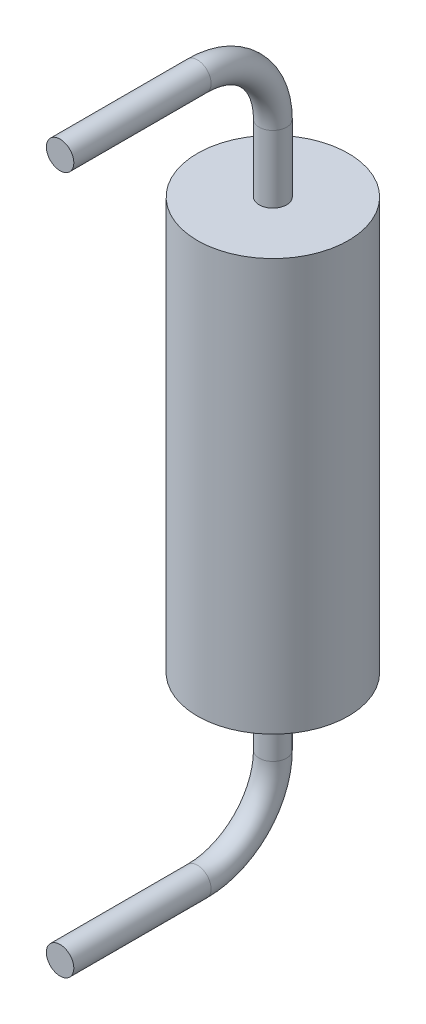
from build123d import *

# Parameters (mm, degrees)
BOSS_EXTRUDE1_DEPTH      = 3
BOSS_EXTRUDE1_DEPTH_BACK = 3
SKETCH2_R                = 1.1
SWEEP1_PROFILE_R         = 0.2


with BuildPart() as part:
    # Sketch2 → Boss-Extrude1 (new, two sides: drawn at the far end of the back side and taken through both)
    with BuildSketch(Plane(origin=(0, 0, 0), x_dir=(1, 0, 0), z_dir=(0, 1, 0)).offset(-BOSS_EXTRUDE1_DEPTH_BACK)):
        Circle(SKETCH2_R)
    extrude(amount=BOSS_EXTRUDE1_DEPTH + BOSS_EXTRUDE1_DEPTH_BACK)

    # Sweep1: sweep along a path in Sketch3
    with BuildLine(Plane(origin=(0, 0, 0), x_dir=(0, 0, -1), z_dir=(1, 0, 0))) as sweep1_path:
        Line((0, 3), (0, 3.98))
        ThreePointArc((0, 3.98), (-0.322182541, 4.757817459), (-1.1, 5.08))
        Line((-1.1, 5.08), (-3.1, 5.08))
    # Sweep1 profile (on start of the path) → Sweep1 (sweep)
    with BuildSketch(Plane.ZX.offset(3)):
        Circle(SWEEP1_PROFILE_R)
    sweep1 = sweep(path=sweep1_path.line)

    # Mirror1: Sweep1 across plane
    add(sweep1.mirror(Plane.ZX))


solid = part.part
